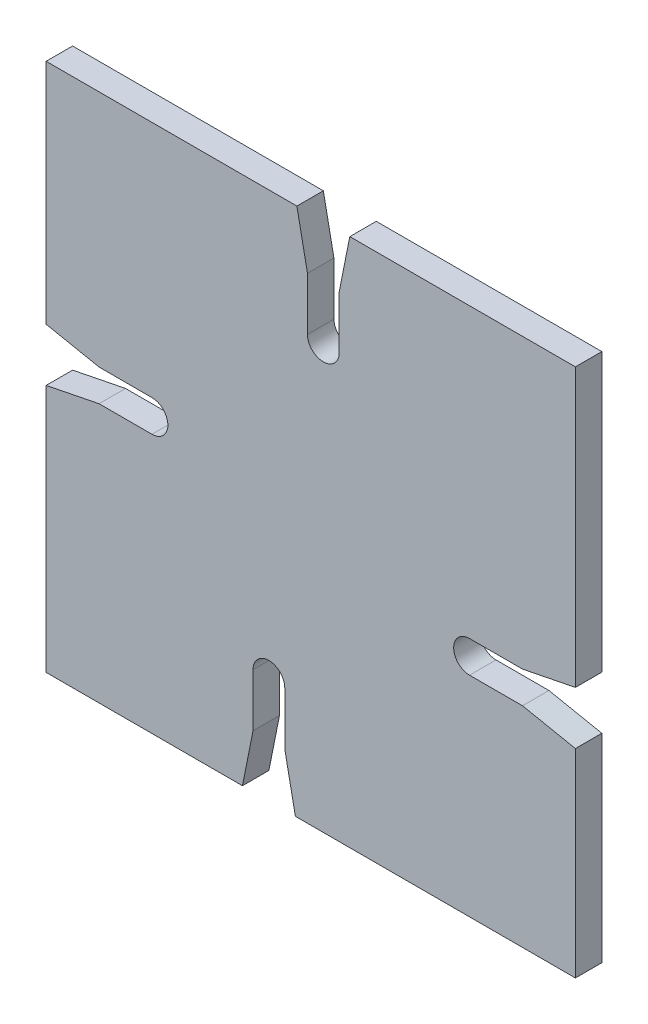
from build123d import *

# Parameters (mm, degrees)
SKIZZE1_W                        = 100
SKIZZE1_H                        = 100
AUFSATZ_LINEAR_AUSTRAGEN1_DEPTH  = 5
SCHNITT_LINEAR_AUSTRAGEN1_REACH  = 7
SCHNITT_LINEAR_AUSTRAGEN14_REACH = 7
SCHNITT_LINEAR_AUSTRAGEN15_REACH = 7
SCHNITT_LINEAR_AUSTRAGEN16_REACH = 7


with BuildPart() as part:
    # Skizze1 → Aufsatz-Linear austragen1 (new body)
    with BuildSketch(Plane.XY):
        with Locations((50, 50)):
            Rectangle(SKIZZE1_W, SKIZZE1_H)
    extrude(amount=AUFSATZ_LINEAR_AUSTRAGEN1_DEPTH)

    # Skizze2 → Schnitt-Linear austragen1 (cut, up to next)
    with BuildSketch(Plane(origin=(61.541641428, 22.675716927, 5), x_dir=(1, 0, 0), z_dir=(0, 0, 1)), mode=Mode.PRIVATE) as schnitt_linear_austragen1_sk1:
        with BuildLine():
            Line((-24.45087326, -22.675716927), (-22.45087326, -12.675716927))
            Line((-22.45087326, -12.675716927), (-22.45087326, -2.675716927))
            ThreePointArc((-22.45087326, -2.675716927), (-19.45087326, 0.324283073), (-16.45087326, -2.675716927))
            Line((-16.45087326, -2.675716927), (-16.45087326, -12.675716927))
            Line((-16.45087326, -12.675716927), (-14.45087326, -22.675716927))
            Line((-14.45087326, -22.675716927), (-24.45087326, -22.675716927))
        make_face()
    schnitt_linear_austragen1_tool1 = extrude(schnitt_linear_austragen1_sk1.sketch, amount=-SCHNITT_LINEAR_AUSTRAGEN1_REACH, mode=Mode.PRIVATE) & part.part
    add(schnitt_linear_austragen1_tool1.solids().sort_by_distance((42.090768, 10.16893, 5))[0], mode=Mode.SUBTRACT)

    # Skizze24 → Schnitt-Linear austragen14 (cut, up to next)
    with BuildSketch(Plane(origin=(44.055881927, 74.466743066, 5), x_dir=(1, 0, 0), z_dir=(0, 0, 1)), mode=Mode.PRIVATE) as schnitt_linear_austragen14_sk1:
        with BuildLine():
            Line((-44.055881927, -17.5), (-34.055881927, -19.5))
            Line((-34.055881927, -19.5), (-24.055881927, -19.5))
            ThreePointArc((-24.055881927, -19.5), (-21.055881927, -22.5), (-24.055881927, -25.5))
            Line((-24.055881927, -25.5), (-34.055881927, -25.5))
            Line((-34.055881927, -25.5), (-44.055881927, -27.5))
            Line((-44.055881927, -27.5), (-44.055881927, -17.5))
        make_face()
    schnitt_linear_austragen14_tool1 = extrude(schnitt_linear_austragen14_sk1.sketch, amount=-SCHNITT_LINEAR_AUSTRAGEN14_REACH, mode=Mode.PRIVATE) & part.part
    add(schnitt_linear_austragen14_tool1.solids().sort_by_distance((10.16893, 51.966743, 5))[0], mode=Mode.SUBTRACT)

    # Skizze25 → Schnitt-Linear austragen15 (cut, up to next)
    with BuildSketch(Plane(origin=(81.625168415, 83.365494521, 5), x_dir=(1, 0, 0), z_dir=(0, 0, 1)), mode=Mode.PRIVATE) as schnitt_linear_austragen15_sk1:
        with BuildLine():
            Line((-24.247626507, 16.634505479), (-26.247626507, 6.634505479))
            Line((-26.247626507, 6.634505479), (-26.247626507, -3.365494521))
            ThreePointArc((-26.247626507, -3.365494521), (-29.247626507, -6.365494521), (-32.247626507, -3.365494521))
            Line((-32.247626507, -3.365494521), (-32.247626507, 6.634505479))
            Line((-32.247626507, 6.634505479), (-34.247626507, 16.634505479))
            Line((-34.247626507, 16.634505479), (-24.247626507, 16.634505479))
        make_face()
    schnitt_linear_austragen15_tool1 = extrude(schnitt_linear_austragen15_sk1.sketch, amount=-SCHNITT_LINEAR_AUSTRAGEN15_REACH, mode=Mode.PRIVATE) & part.part
    add(schnitt_linear_austragen15_tool1.solids().sort_by_distance((52.377542, 89.83107, 5))[0], mode=Mode.SUBTRACT)

    # Skizze26 → Schnitt-Linear austragen16 (cut, up to next)
    with BuildSketch(Plane(origin=(95.870397917, 55.045051389, 5), x_dir=(1, 0, 0), z_dir=(0, 0, 1)), mode=Mode.PRIVATE) as schnitt_linear_austragen16_sk1:
        with BuildLine():
            Line((4.129602083, -17.5), (-5.870397917, -15.5))
            Line((-5.870397917, -15.5), (-15.870397917, -15.5))
            ThreePointArc((-15.870397917, -15.5), (-18.870397917, -12.5), (-15.870397917, -9.5))
            Line((-15.870397917, -9.5), (-5.870397917, -9.5))
            Line((-5.870397917, -9.5), (4.129602083, -7.5))
            Line((4.129602083, -7.5), (4.129602083, -17.5))
        make_face()
    schnitt_linear_austragen16_tool1 = extrude(schnitt_linear_austragen16_sk1.sketch, amount=-SCHNITT_LINEAR_AUSTRAGEN16_REACH, mode=Mode.PRIVATE) & part.part
    add(schnitt_linear_austragen16_tool1.solids().sort_by_distance((89.83107, 42.545051, 5))[0], mode=Mode.SUBTRACT)


solid = part.part
